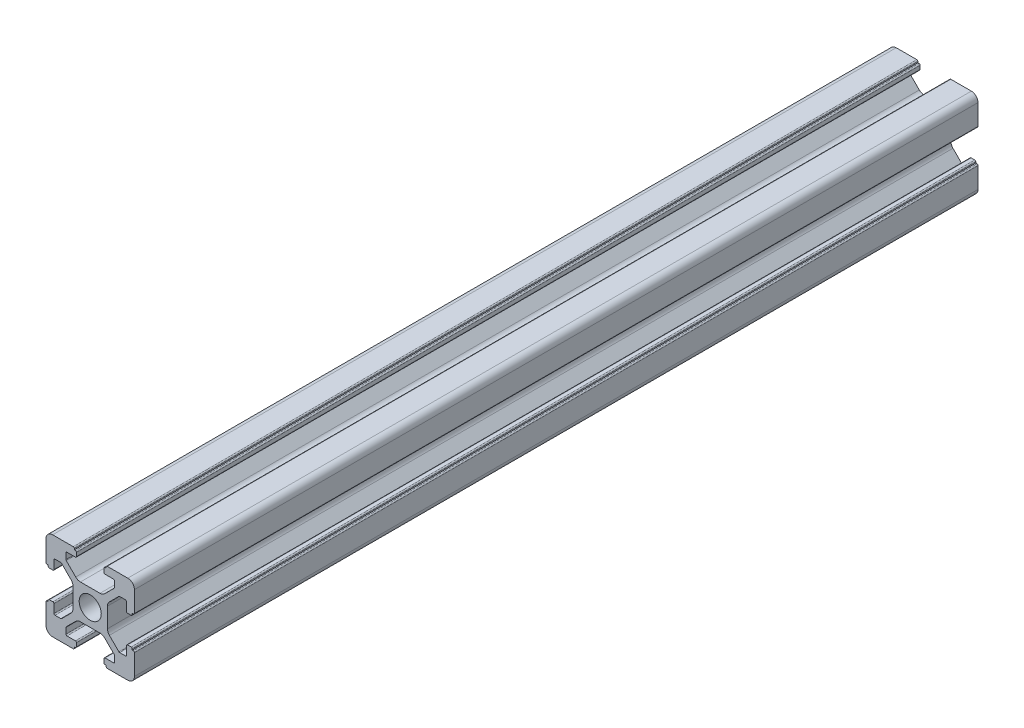
from build123d import *

# Parameters (mm, degrees)
SKETCH_1_R      = 2.5
EXTRUDE_1_DEPTH = 190.86


with BuildPart() as part:
    # 草图1 → 凸台-拉伸1 (new body)
    with BuildSketch(Plane.XY):
        with BuildLine():
            Line((-8.502261885, -10.002261885), (-3.85, -10.002261885))
            ThreePointArc((-3.85, -10.002261885), (-3.673223305, -9.929038581), (-3.6, -9.752261885))
            Line((-3.6, -9.752261885), (-3.6, -9.502261885))
            Line((-3.6, -9.502261885), (-3.35, -9.502261885))
            ThreePointArc((-3.35, -9.502261885), (-3.173223305, -9.429038581), (-3.1, -9.252261885))
            Line((-3.1, -9.252261885), (-3.1, -8.45))
            ThreePointArc((-3.1, -8.45), (-3.173223305, -8.273223305), (-3.35, -8.2))
            Line((-3.35, -8.2), (-5.25, -8.2))
            ThreePointArc((-5.25, -8.2), (-5.426776695, -8.126776695), (-5.5, -7.95))
            Line((-5.5, -7.95), (-5.5, -6.664213562))
            ThreePointArc((-5.5, -6.664213562), (-5.480969883, -6.568542704), (-5.426776695, -6.487436867))
            Line((-5.426776695, -6.487436867), (-3.278679656, -4.339339828))
            ThreePointArc((-3.278679656, -4.339339828), (-2.792044633, -4.014180701), (-2.218019485, -3.9))
            Line((-2.218019485, -3.9), (2.218019485, -3.9))
            ThreePointArc((2.218019485, -3.9), (2.792044633, -4.014180701), (3.278679656, -4.339339828))
            Line((3.278679656, -4.339339828), (5.426776695, -6.487436867))
            ThreePointArc((5.426776695, -6.487436867), (5.480969883, -6.568542704), (5.5, -6.664213562))
            Line((5.5, -6.664213562), (5.5, -7.95))
            ThreePointArc((5.5, -7.95), (5.426776695, -8.126776695), (5.25, -8.2))
            Line((5.25, -8.2), (3.35, -8.2))
            ThreePointArc((3.35, -8.2), (3.173223305, -8.273223305), (3.1, -8.45))
            Line((3.1, -8.45), (3.1, -9.252261885))
            ThreePointArc((3.1, -9.252261885), (3.173223305, -9.429038581), (3.35, -9.502261885))
            Line((3.35, -9.502261885), (3.6, -9.502261885))
            Line((3.6, -9.502261885), (3.6, -9.752261885))
            ThreePointArc((3.6, -9.752261885), (3.673223305, -9.929038581), (3.85, -10.002261885))
            Line((3.85, -10.002261885), (8.502261885, -10.002261885))
            ThreePointArc((8.502261885, -10.002261885), (9.562922057, -9.562922057), (10.002261885, -8.502261885))
            Line((10.002261885, -8.502261885), (10.002261885, -3.85))
            ThreePointArc((10.002261885, -3.85), (9.929038581, -3.673223305), (9.752261885, -3.6))
            Line((9.752261885, -3.6), (9.502261885, -3.6))
            Line((9.502261885, -3.6), (9.502261885, -3.35))
            ThreePointArc((9.502261885, -3.35), (9.429038581, -3.173223305), (9.252261885, -3.1))
            Line((9.252261885, -3.1), (8.45, -3.1))
            ThreePointArc((8.45, -3.1), (8.273223305, -3.173223305), (8.2, -3.35))
            Line((8.2, -3.35), (8.2, -5.25))
            ThreePointArc((8.2, -5.25), (8.126776695, -5.426776695), (7.95, -5.5))
            Line((7.95, -5.5), (6.664213562, -5.5))
            ThreePointArc((6.664213562, -5.5), (6.568542704, -5.480969883), (6.487436867, -5.426776695))
            Line((6.487436867, -5.426776695), (4.339339828, -3.278679656))
            ThreePointArc((4.339339828, -3.278679656), (4.014180701, -2.792044633), (3.9, -2.218019485))
            Line((3.9, -2.218019485), (3.9, 2.218019485))
            ThreePointArc((3.9, 2.218019485), (4.014180701, 2.792044633), (4.339339828, 3.278679656))
            Line((4.339339828, 3.278679656), (6.487436867, 5.426776695))
            ThreePointArc((6.487436867, 5.426776695), (6.568542704, 5.480969883), (6.664213562, 5.5))
            Line((6.664213562, 5.5), (7.95, 5.5))
            ThreePointArc((7.95, 5.5), (8.126776695, 5.426776695), (8.2, 5.25))
            Line((8.2, 5.25), (8.2, 3.35))
            ThreePointArc((8.2, 3.35), (8.273223305, 3.173223305), (8.45, 3.1))
            Line((8.45, 3.1), (9.252261885, 3.1))
            ThreePointArc((9.252261885, 3.1), (9.429038581, 3.173223305), (9.502261885, 3.35))
            Line((9.502261885, 3.35), (9.502261885, 3.6))
            Line((9.502261885, 3.6), (9.752261885, 3.6))
            ThreePointArc((9.752261885, 3.6), (9.929038581, 3.673223305), (10.002261885, 3.85))
            Line((10.002261885, 3.85), (10.002261885, 8.502261885))
            ThreePointArc((10.002261885, 8.502261885), (9.562922057, 9.562922057), (8.502261885, 10.002261885))
            Line((8.502261885, 10.002261885), (3.85, 10.002261885))
            ThreePointArc((3.85, 10.002261885), (3.673223305, 9.929038581), (3.6, 9.752261885))
            Line((3.6, 9.752261885), (3.6, 9.502261885))
            Line((3.6, 9.502261885), (3.35, 9.502261885))
            ThreePointArc((3.35, 9.502261885), (3.173223305, 9.429038581), (3.1, 9.252261885))
            Line((3.1, 9.252261885), (3.1, 8.45))
            ThreePointArc((3.1, 8.45), (3.173223305, 8.273223305), (3.35, 8.2))
            Line((3.35, 8.2), (5.25, 8.2))
            ThreePointArc((5.25, 8.2), (5.426776695, 8.126776695), (5.5, 7.95))
            Line((5.5, 7.95), (5.5, 6.664213562))
            ThreePointArc((5.5, 6.664213562), (5.480969883, 6.568542704), (5.426776695, 6.487436867))
            Line((5.426776695, 6.487436867), (3.278679656, 4.339339828))
            ThreePointArc((3.278679656, 4.339339828), (2.792044633, 4.014180701), (2.218019485, 3.9))
            Line((2.218019485, 3.9), (-2.218019485, 3.9))
            ThreePointArc((-2.218019485, 3.9), (-2.792044633, 4.014180701), (-3.278679656, 4.339339828))
            Line((-3.278679656, 4.339339828), (-5.426776695, 6.487436867))
            ThreePointArc((-5.426776695, 6.487436867), (-5.480969883, 6.568542704), (-5.5, 6.664213562))
            Line((-5.5, 6.664213562), (-5.5, 7.95))
            ThreePointArc((-5.5, 7.95), (-5.426776695, 8.126776695), (-5.25, 8.2))
            Line((-5.25, 8.2), (-3.35, 8.2))
            ThreePointArc((-3.35, 8.2), (-3.173223305, 8.273223305), (-3.1, 8.45))
            Line((-3.1, 8.45), (-3.1, 9.252261885))
            ThreePointArc((-3.1, 9.252261885), (-3.173223305, 9.429038581), (-3.35, 9.502261885))
            Line((-3.35, 9.502261885), (-3.6, 9.502261885))
            Line((-3.6, 9.502261885), (-3.6, 9.752261885))
            ThreePointArc((-3.6, 9.752261885), (-3.673223305, 9.929038581), (-3.85, 10.002261885))
            Line((-3.85, 10.002261885), (-8.502261885, 10.002261885))
            ThreePointArc((-8.502261885, 10.002261885), (-9.562922057, 9.562922057), (-10.002261885, 8.502261885))
            Line((-10.002261885, 8.502261885), (-10.002261885, 3.85))
            ThreePointArc((-10.002261885, 3.85), (-9.929038581, 3.673223305), (-9.752261885, 3.6))
            Line((-9.752261885, 3.6), (-9.502261885, 3.6))
            Line((-9.502261885, 3.6), (-9.502261885, 3.35))
            ThreePointArc((-9.502261885, 3.35), (-9.429038581, 3.173223305), (-9.252261885, 3.1))
            Line((-9.252261885, 3.1), (-8.45, 3.1))
            ThreePointArc((-8.45, 3.1), (-8.273223305, 3.173223305), (-8.2, 3.35))
            Line((-8.2, 3.35), (-8.2, 5.25))
            ThreePointArc((-8.2, 5.25), (-8.126776695, 5.426776695), (-7.95, 5.5))
            Line((-7.95, 5.5), (-6.664213562, 5.5))
            ThreePointArc((-6.664213562, 5.5), (-6.568542704, 5.480969883), (-6.487436867, 5.426776695))
            Line((-6.487436867, 5.426776695), (-4.339339828, 3.278679656))
            ThreePointArc((-4.339339828, 3.278679656), (-4.014180701, 2.792044633), (-3.9, 2.218019485))
            Line((-3.9, 2.218019485), (-3.9, -2.218019485))
            ThreePointArc((-3.9, -2.218019485), (-4.014180701, -2.792044633), (-4.339339828, -3.278679656))
            Line((-4.339339828, -3.278679656), (-6.487436867, -5.426776695))
            ThreePointArc((-6.487436867, -5.426776695), (-6.568542704, -5.480969883), (-6.664213562, -5.5))
            Line((-6.664213562, -5.5), (-7.95, -5.5))
            ThreePointArc((-7.95, -5.5), (-8.126776695, -5.426776695), (-8.2, -5.25))
            Line((-8.2, -5.25), (-8.2, -3.35))
            ThreePointArc((-8.2, -3.35), (-8.273223305, -3.173223305), (-8.45, -3.1))
            Line((-8.45, -3.1), (-9.252261885, -3.1))
            ThreePointArc((-9.252261885, -3.1), (-9.429038581, -3.173223305), (-9.502261885, -3.35))
            Line((-9.502261885, -3.35), (-9.502261885, -3.6))
            Line((-9.502261885, -3.6), (-9.752261885, -3.6))
            ThreePointArc((-9.752261885, -3.6), (-9.929038581, -3.673223305), (-10.002261885, -3.85))
            Line((-10.002261885, -3.85), (-10.002261885, -8.502261885))
            ThreePointArc((-10.002261885, -8.502261885), (-9.562922057, -9.562922057), (-8.502261885, -10.002261885))
        make_face()
        Circle(SKETCH_1_R, mode=Mode.SUBTRACT)
    extrude(amount=EXTRUDE_1_DEPTH)


solid = part.part
